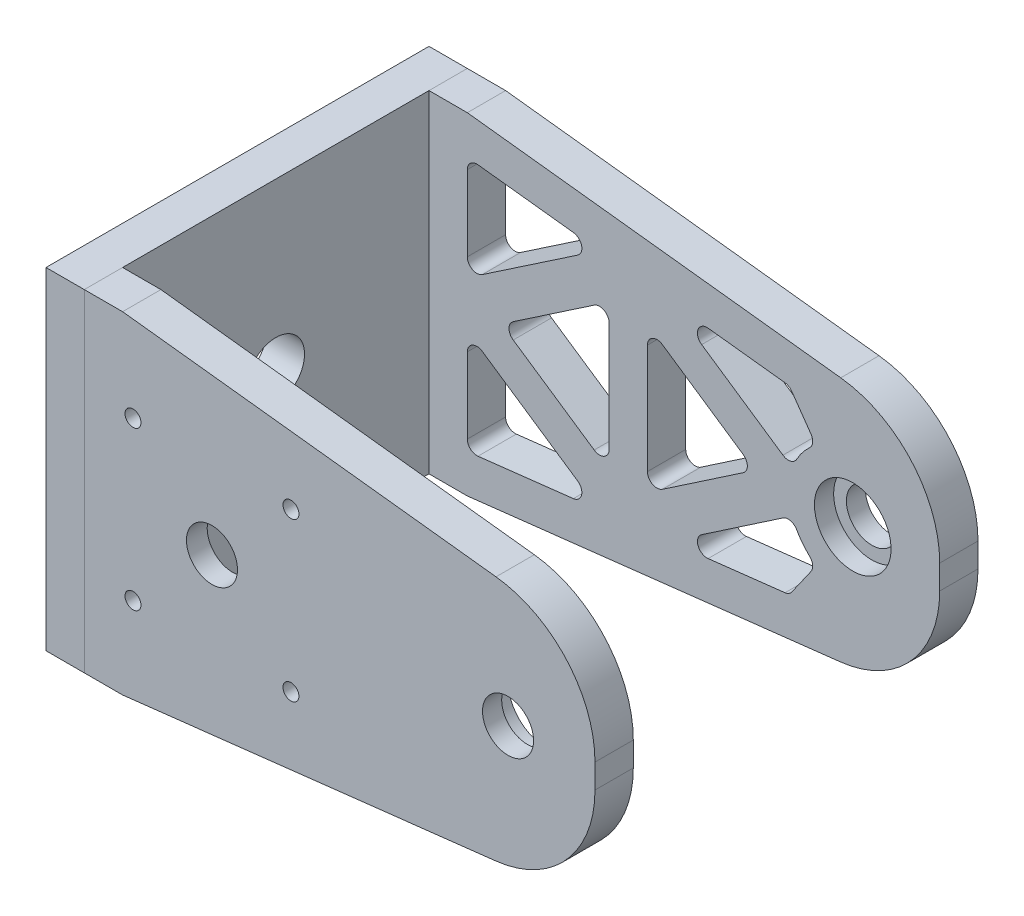
from build123d import *

# Parameters (mm, degrees)
SKETCH1_W               = 104
SKETCH1_H               = 120
SKETCH1_R               = 9
BOSS_EXTRUDE1_DEPTH     = 12
SKETCH2_W               = 104
SKETCH2_H               = 12
BOSS_EXTRUDE3_DEPTH     = 160
SKETCH3_R               = 8
SKETCH3_R_2             = 2.5
CUT_EXTRUDE1_DEPTH      = 20
SKETCH3_3_R             = 25
CUT_EXTRUDE2_DEPTH      = 5.5
SKETCH3_4_W             = 70
SKETCH3_4_H             = 70
CUT_EXTRUDE3_DEPTH      = 2
FILLET1_R               = 6
SKETCH3_5_R             = 8
CUT_EXTRUDE4_DEPTH      = 109
CUT_EXTRUDE4_DEPTH_BACK = 13
SKETCH3_6_R             = 12
SKETCH3_6_R_2           = 8
CUT_EXTRUDE5_DEPTH      = 6
CUT_EXTRUDE6_START      = 96
SKETCH3_7_R             = 12
CUT_EXTRUDE6_DEPTH      = 6
CUT_EXTRUDE7_DEPTH      = 1
CUT_EXTRUDE7_DEPTH_BACK = 121
CUT_EXTRUDE8_DEPTH      = 1
CUT_EXTRUDE8_DEPTH_BACK = 20


with BuildPart() as part:
    # Sketch1 → Boss-Extrude1 (new body)
    with BuildSketch(Plane.YZ):
        Rectangle(SKETCH1_W, SKETCH1_H)
        Circle(SKETCH1_R, mode=Mode.SUBTRACT)
    extrude(amount=BOSS_EXTRUDE1_DEPTH)


with BuildPart() as body_2:
    # Sketch2 → Boss-Extrude3 (new body)
    with BuildSketch(Plane.YZ.offset(12)):
        with Locations((0, 54)):
            Rectangle(SKETCH2_W, SKETCH2_H)
    extrude(amount=BOSS_EXTRUDE3_DEPTH)


with BuildPart() as body_3:
    # Mirror2: mirrored copy
    add(body_2.part.mirror(Plane.XY))


with BuildPart() as body_2_1:
    add(body_2.part)

    # Sketch3 → Cut-Extrude1 (cut)
    with BuildSketch(Plane(origin=(0, 0, 48), x_dir=(1, 0, 0), z_dir=(0, 0, -1))):
        with Locations((52, 0)):
            Circle(SKETCH3_R)
        with Locations((27.251262658, 24.748737342)):
            Circle(SKETCH3_R_2)
        with Locations((76.748737342, 24.748737342)):
            Circle(SKETCH3_R_2)
        with Locations((76.748737342, -24.748737342)):
            Circle(SKETCH3_R_2)
        with Locations((27.251262658, -24.748737342)):
            Circle(SKETCH3_R_2)
    extrude(amount=-CUT_EXTRUDE1_DEPTH, mode=Mode.SUBTRACT)

    # Sketch3_3 → Cut-Extrude2 (cut)
    with BuildSketch(Plane(origin=(0, 0, 48), x_dir=(1, 0, 0), z_dir=(0, 0, -1))):
        with Locations((52, 0)):
            Circle(SKETCH3_3_R)
    extrude(amount=-CUT_EXTRUDE2_DEPTH, mode=Mode.SUBTRACT)

    # Sketch3_4 → Cut-Extrude3 (cut)
    with BuildSketch(Plane(origin=(0, 0, 48), x_dir=(1, 0, 0), z_dir=(0, 0, -1))):
        with Locations((52, 0)):
            Rectangle(SKETCH3_4_W, SKETCH3_4_H)
    extrude(amount=-CUT_EXTRUDE3_DEPTH, mode=Mode.SUBTRACT)

    # Fillet1
    fillet1_edges = [body_2_1.edges().sort_by_distance(p)[0] for p in [
        (17, 35, 49),
        (17, -35, 49),
        (87, -35, 49),
        (87, 35, 49),
    ]]
    fillet(fillet1_edges, radius=FILLET1_R)


with BuildPart() as cut_extrude4_tool:
    # Sketch3_5 → Cut-Extrude4 (new body, two sides)
    with BuildSketch(Plane(origin=(0, 0, 48), x_dir=(1, 0, 0), z_dir=(0, 0, -1))) as cut_extrude4_sk:
        with Locations((144.763523684, 0)):
            Circle(SKETCH3_5_R)
    extrude(amount=CUT_EXTRUDE4_DEPTH)
    extrude(cut_extrude4_sk.sketch, amount=-CUT_EXTRUDE4_DEPTH_BACK)


with BuildPart() as body_2_2:
    add(body_2_1.part)

    # Cut-Extrude4: cut by cut_extrude4_tool
    add(cut_extrude4_tool.part, mode=Mode.SUBTRACT)

    # Sketch3_6 → Cut-Extrude5 (cut)
    with BuildSketch(Plane(origin=(0, 0, 48), x_dir=(1, 0, 0), z_dir=(0, 0, -1))):
        with Locations((144.763523684, 0)):
            Circle(SKETCH3_6_R)
        with Locations((144.763523684, 0)):
            Circle(SKETCH3_6_R_2, mode=Mode.SUBTRACT)
    extrude(amount=-CUT_EXTRUDE5_DEPTH, mode=Mode.SUBTRACT)


with BuildPart() as body_3_1:
    add(body_3.part)

    # Cut-Extrude4: cut by cut_extrude4_tool
    add(cut_extrude4_tool.part, mode=Mode.SUBTRACT)

    # Sketch3_7 → Cut-Extrude6 (cut)
    with BuildSketch(Plane(origin=(0, 0, 48), x_dir=(1, 0, 0), z_dir=(0, 0, -1)).offset(CUT_EXTRUDE6_START)):
        with Locations((144.763523684, 0)):
            Circle(SKETCH3_7_R)
    extrude(amount=CUT_EXTRUDE6_DEPTH, mode=Mode.SUBTRACT)


with BuildPart() as cut_extrude7_tool:
    # Sketch4 → Cut-Extrude7 (new body, two sides)
    with BuildSketch(Plane(origin=(0, 0, -60), x_dir=(1, 0, 0), z_dir=(0, 0, -1))) as cut_extrude7_sk:
        with BuildLine():
            Line((24, 52), (140.994008264, 38.561499051))
            ThreePointArc((140.994008264, 38.561499051), (163.122694054, 27.084013199), (172, 3.790132986))
            Line((172, 3.790132986), (172, 52))
            Line((172, 52), (24, 52))
        make_face()
        with BuildLine():
            Line((24, -52), (140.994008264, -38.561499051))
            ThreePointArc((140.994008264, -38.561499051), (163.122694054, -27.084013199), (172, -3.790132986))
            Line((172, -3.790132986), (172, -52))
            Line((172, -52), (24, -52))
        make_face()
    extrude(amount=CUT_EXTRUDE7_DEPTH)
    extrude(cut_extrude7_sk.sketch, amount=-CUT_EXTRUDE7_DEPTH_BACK)


with BuildPart() as body_2_3:
    add(body_2_2.part)

    # Cut-Extrude7: cut by cut_extrude7_tool
    add(cut_extrude7_tool.part, mode=Mode.SUBTRACT)


with BuildPart() as body_3_2:
    add(body_3_1.part)

    # Cut-Extrude7: cut by cut_extrude7_tool
    add(cut_extrude7_tool.part, mode=Mode.SUBTRACT)

    # Sketch5 → Cut-Extrude8 (cut, two sides)
    with BuildSketch(Plane(origin=(0, 0, -60), x_dir=(1, 0, 0), z_dir=(0, 0, -1))) as cut_extrude8_sk:
        with BuildLine():
            Line((38.378018651, 2.484618931), (63.750146093, 19.653205971))
            ThreePointArc((63.750146093, 19.653205971), (66.83786374, 19.81847477), (68.43141608, 17.168587041))
            Line((68.43141608, 17.168587041), (68.43141608, -17.168587041))
            ThreePointArc((68.43141608, -17.168587041), (66.83786374, -19.81847477), (63.750146093, -19.653205971))
            Line((63.750146093, -19.653205971), (38.378018651, -2.484618931))
            ThreePointArc((38.378018651, -2.484618931), (37.059288638, 0), (38.378018651, 2.484618931))
        make_face()
        with BuildLine():
            Line((85.11512205, 19.636271681), (110.411175563, 2.482968829))
            ThreePointArc((110.411175563, 2.482968829), (111.727469593, 0), (110.411175563, -2.482968829))
            Line((110.411175563, -2.482968829), (85.11512205, -19.636271681))
            ThreePointArc((85.11512205, -19.636271681), (82.026268029, -19.80387995), (80.43141608, -17.153302852))
            Line((80.43141608, -17.153302852), (80.43141608, 17.153302852))
            ThreePointArc((80.43141608, 17.153302852), (82.026268029, 19.80387995), (85.11512205, 19.636271681))
        make_face()
        with BuildLine():
            Line((28.681269987, 10.412252121), (58.572397099, 30.638715934))
            ThreePointArc((58.572397099, 30.638715934), (59.804950819, 33.837219591), (57.233470678, 36.10373767))
            Line((57.233470678, 36.10373767), (27.342343565, 39.537177946))
            ThreePointArc((27.342343565, 39.537177946), (25.003381696, 38.795863203), (24, 36.556775141))
            Line((24, 36.556775141), (24, 12.896871051))
            ThreePointArc((24, 12.896871051), (25.59355234, 10.246983322), (28.681269987, 10.412252121))
        make_face()
        with BuildLine():
            Line((97.419038917, 25.791734264), (122.88439953, 8.523623939))
            ThreePointArc((122.88439953, 8.523623939), (125.275265792, 8.0911298), (127.20229048, 9.570950233))
            ThreePointArc((127.20229048, 9.570950233), (129.005827387, 12.316452712), (131.234448999, 14.729702583))
            ThreePointArc((131.234448999, 14.729702583), (132.187652387, 16.616189766), (131.660366854, 18.662992286))
            Line((131.660366854, 18.662992286), (125.644209857, 27.231880919))
            ThreePointArc((125.644209857, 27.231880919), (124.722362956, 28.086531783), (123.531274365, 28.488449409))
            Line((123.531274365, 28.488449409), (99.445088452, 31.255105899))
            ThreePointArc((99.445088452, 31.255105899), (96.289931227, 29.317813499), (97.419038917, 25.791734264))
        make_face()
        with BuildLine():
            Line((97.419038917, -25.791734264), (122.88439953, -8.523623939))
            ThreePointArc((122.88439953, -8.523623939), (125.275265792, -8.0911298), (127.20229048, -9.570950233))
            ThreePointArc((127.20229048, -9.570950233), (129.005827387, -12.316452712), (131.234448999, -14.729702583))
            ThreePointArc((131.234448999, -14.729702583), (132.187652387, -16.616189766), (131.660366854, -18.662992286))
            Line((131.660366854, -18.662992286), (125.644209857, -27.231880919))
            ThreePointArc((125.644209857, -27.231880919), (124.722362956, -28.086531783), (123.531274365, -28.488449409))
            Line((123.531274365, -28.488449409), (99.445088452, -31.255105899))
            ThreePointArc((99.445088452, -31.255105899), (96.289931227, -29.317813499), (97.419038917, -25.791734264))
        make_face()
        with BuildLine():
            Line((28.681269987, -10.412252121), (58.572397099, -30.638715934))
            ThreePointArc((58.572397099, -30.638715934), (59.804950819, -33.837219591), (57.233470678, -36.10373767))
            Line((57.233470678, -36.10373767), (27.342343565, -39.537177946))
            ThreePointArc((27.342343565, -39.537177946), (25.003381696, -38.795863203), (24, -36.556775141))
            Line((24, -36.556775141), (24, -12.896871051))
            ThreePointArc((24, -12.896871051), (25.59355234, -10.246983322), (28.681269987, -10.412252121))
        make_face()
    extrude(amount=CUT_EXTRUDE8_DEPTH, mode=Mode.SUBTRACT)
    extrude(cut_extrude8_sk.sketch, amount=-CUT_EXTRUDE8_DEPTH_BACK, mode=Mode.SUBTRACT)


solid = Compound([part.part, body_2_3.part, body_3_2.part])
